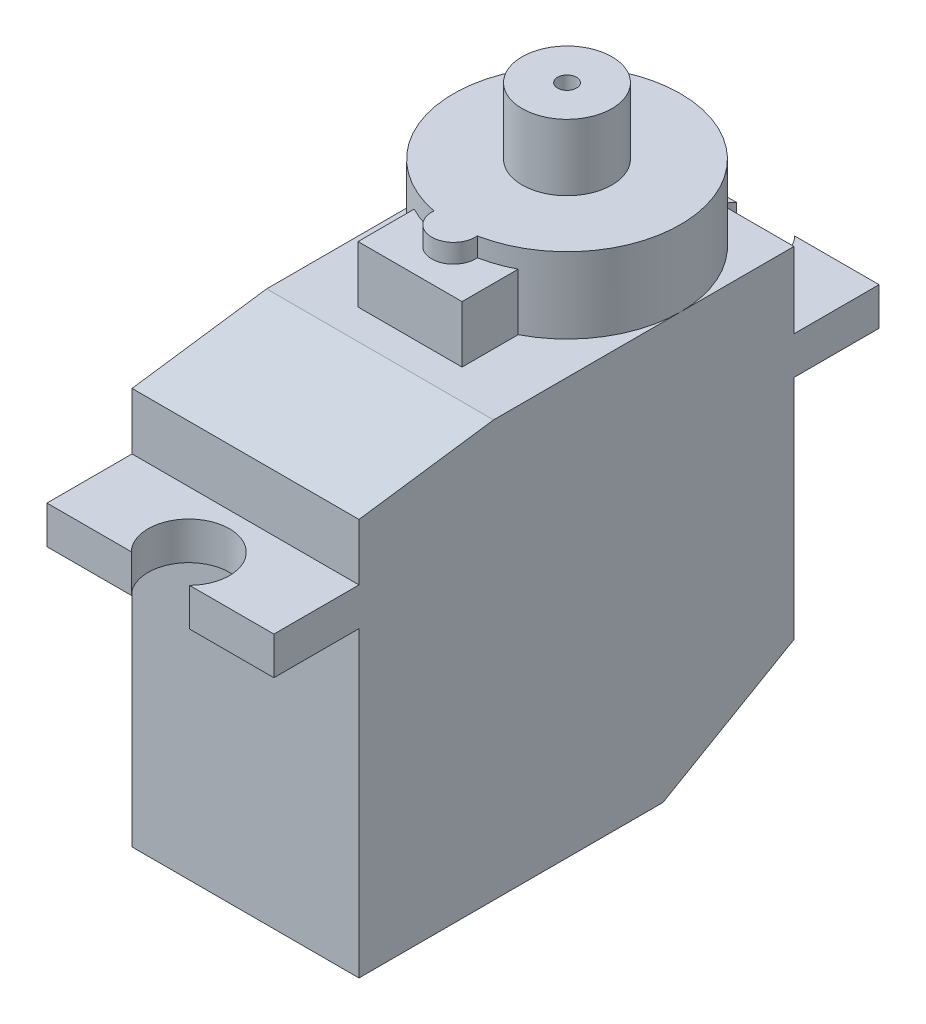
from build123d import *

# Parameters (mm, degrees)
SKETCH1_W           = 12
SKETCH1_H           = 23
BOSS_EXTRUDE1_DEPTH = 22
CHAMFER1_SIZE       = 4
CHAMFER1_SIZE2      = 6.92820323
BOSS_EXTRUDE2_DEPTH = 2
SKETCH3_R           = 6
BOSS_EXTRUDE3_DEPTH = 4
SKETCH4_W           = 5.5
SKETCH4_H           = 8.3
BOSS_EXTRUDE4_DEPTH = 3
SKETCH5_R           = 1.15
BOSS_EXTRUDE5_DEPTH = 1
SKETCH6_R           = 2.375
SKETCH6_R_2         = 0.5
BOSS_EXTRUDE6_DEPTH = 3.5
CHAMFER2_SIZE       = 1
CHAMFER2_SIZE2      = 7.115369722


with BuildPart() as part:
    # Sketch1 → Boss-Extrude1 (new body)
    with BuildSketch(Plane(origin=(0, 0, 0), x_dir=(1, 0, 0), z_dir=(0, 1, 0))):
        with Locations((0, -5.5)):
            Rectangle(SKETCH1_W, SKETCH1_H)
    extrude(amount=BOSS_EXTRUDE1_DEPTH)

    # Chamfer1
    chamfer1_edges = [part.edges().sort_by_distance(p)[0] for p in [
        (0, 0, -6),
    ]]
    chamfer1_side = [part.faces().sort_by_distance(p)[0] for p in [
        (0, 11, -6),
    ]]
    chamfer(chamfer1_edges, length=CHAMFER1_SIZE, length2=CHAMFER1_SIZE2, reference=chamfer1_side[0])

    # Sketch2 → Boss-Extrude2 (add)
    with BuildSketch(Plane(origin=(0, 16, 0), x_dir=(-1, 0, 0), z_dir=(0, 1, 0))):
        with BuildLine():
            Line((6, -6), (6, -10.5))
            Line((6, -10.5), (1.54029218, -10.5))
            ThreePointArc((1.54029218, -10.5), (0, -6.85), (-1.54029218, -10.5))
            Line((-1.54029218, -10.5), (-6, -10.5))
            Line((-6, -10.5), (-6, -6))
            Line((-6, -6), (6, -6))
        make_face()
        with BuildLine():
            Line((-6, 21.5), (-1.54029218, 21.5))
            ThreePointArc((-1.54029218, 21.5), (0, 17.85), (1.54029218, 21.5))
            Line((1.54029218, 21.5), (6, 21.5))
            Line((6, 21.5), (6, 17))
            Line((6, 17), (-6, 17))
            Line((-6, 17), (-6, 21.5))
        make_face()
    extrude(amount=BOSS_EXTRUDE2_DEPTH)

    # Sketch3 → Boss-Extrude3 (add)
    with BuildSketch(Plane(origin=(0, 22, 0), x_dir=(1, 0, 0), z_dir=(0, 1, 0))):
        Circle(SKETCH3_R)
    extrude(amount=BOSS_EXTRUDE3_DEPTH)

    # Sketch4 → Boss-Extrude4 (add)
    with BuildSketch(Plane(origin=(0, 22, 0), x_dir=(1, 0, 0), z_dir=(0, 1, 0))):
        with Locations((0, -4.15)):
            Rectangle(SKETCH4_W, SKETCH4_H)
    extrude(amount=BOSS_EXTRUDE4_DEPTH)

    # Sketch5 → Boss-Extrude5 (add)
    with BuildSketch(Plane(origin=(0, 25, 0), x_dir=(1, 0, 0), z_dir=(0, 1, 0))):
        with Locations((0, -6)):
            Circle(SKETCH5_R)
    extrude(amount=BOSS_EXTRUDE5_DEPTH)

    # Sketch6 → Boss-Extrude6 (add)
    with BuildSketch(Plane(origin=(0, 26, 0), x_dir=(1, 0, 0), z_dir=(0, 1, 0))):
        Circle(SKETCH6_R)
        Circle(SKETCH6_R_2, mode=Mode.SUBTRACT)
    extrude(amount=BOSS_EXTRUDE6_DEPTH)

    # Chamfer2
    chamfer2_edges = [part.edges().sort_by_distance(p)[0] for p in [
        (0, 22, 17),
    ]]
    chamfer2_side = [part.faces().sort_by_distance(p)[0] for p in [
        (0, 20, 17),
    ]]
    chamfer(chamfer2_edges, length=CHAMFER2_SIZE, length2=CHAMFER2_SIZE2, reference=chamfer2_side[0])


solid = part.part
